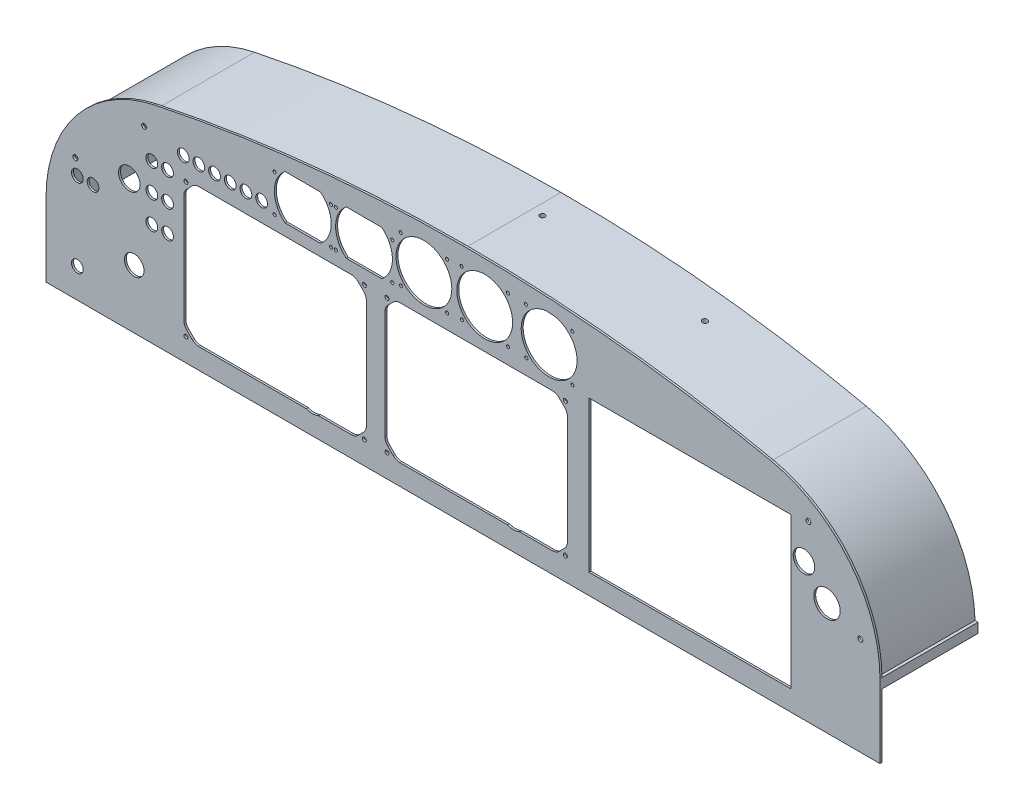
from build123d import *

# Parameters (mm, degrees)
SKETCH1_R           = 6
SKETCH1_R_2         = 2.032
SKETCH1_R_3         = 28.5
SKETCH1_R_4         = 1.6
SKETCH1_R_5         = 13.5
SKETCH1_R_6         = 10
SKETCH1_W           = 206
SKETCH1_H           = 154
BOSS_EXTRUDE1_DEPTH = 2
SKETCH3_R           = 2.5
SKETCH3_R_2         = 11
CUT_EXTRUDE1_DEPTH  = 2
EXTRUDE_THIN1_DEPTH = 100
CUT_EXTRUDE2_REACH  = 245.912
SKETCH6_R           = 2.635
SKETCH6_R_2         = 2.634583067


with BuildPart() as part:
    # Sketch1 → Boss-Extrude1 (new body)
    with BuildSketch(Plane.XY):
        with BuildLine():
            Line((649.441186223, 140.307443973), (649.441186223, 155.307443973))
            Line((649.441186223, 155.307443973), (649.441186223, 215.307443973))
            ThreePointArc((649.441186223, 215.307443973), (680.667313691, 303.445090041), (760.416109856, 352.265630811))
            ThreePointArc((760.416109856, 352.265630811), (916.817397977, 376.984778219), (1074.941186222, 385.307443973))
            ThreePointArc((1074.941186222, 385.307443973), (1233.073283535, 377.06387223), (1389.46626259, 352.265630811))
            ThreePointArc((1389.46626259, 352.265630811), (1469.176407606, 303.413771662), (1500.441186223, 215.307443974))
            Line((1500.441186223, 215.307443974), (1500.441186223, 140.307443973))
            Line((1500.441186223, 140.307443973), (649.441186223, 140.307443973))
        make_face()
        with Locations((853.441186223, 322.307443973)):
            Circle(SKETCH1_R, mode=Mode.SUBTRACT)
        with Locations((869.441186223, 322.307443973)):
            Circle(SKETCH1_R, mode=Mode.SUBTRACT)
        with Locations((997.365509528, 163.658286206)):
            Circle(SKETCH1_R_2, mode=Mode.SUBTRACT)
        with Locations((1179.465509529, 163.658286206)):
            Circle(SKETCH1_R_2, mode=Mode.SUBTRACT)
        with Locations((1179.465509529, 300.358286207)):
            Circle(SKETCH1_R_2, mode=Mode.SUBTRACT)
        with Locations((997.365509528, 300.358286207)):
            Circle(SKETCH1_R_2, mode=Mode.SUBTRACT)
        with Locations((792.197979152, 163.658286206)):
            Circle(SKETCH1_R_2, mode=Mode.SUBTRACT)
        with Locations((974.297979153, 163.658286206)):
            Circle(SKETCH1_R_2, mode=Mode.SUBTRACT)
        with Locations((974.297979153, 300.358286207)):
            Circle(SKETCH1_R_2, mode=Mode.SUBTRACT)
        with Locations((792.197979152, 300.358286207)):
            Circle(SKETCH1_R_2, mode=Mode.SUBTRACT)
        with Locations((1162.812861584, 341.737114485)):
            Circle(SKETCH1_R_3, mode=Mode.SUBTRACT)
        with Locations((1139.124784415, 365.425191654)):
            Circle(SKETCH1_R_4, mode=Mode.SUBTRACT)
        with Locations((1186.500938754, 318.049037315)):
            Circle(SKETCH1_R_4, mode=Mode.SUBTRACT)
        with Locations((1186.500938754, 365.425191654)):
            Circle(SKETCH1_R_4, mode=Mode.SUBTRACT)
        with Locations((1097.100872713, 342.607531463)):
            Circle(SKETCH1_R_3, mode=Mode.SUBTRACT)
        with Locations((1073.412795543, 366.295608633)):
            Circle(SKETCH1_R_4, mode=Mode.SUBTRACT)
        with Locations((1120.788949883, 318.919454293)):
            Circle(SKETCH1_R_4, mode=Mode.SUBTRACT)
        with Locations((1120.788949883, 366.295608633)):
            Circle(SKETCH1_R_4, mode=Mode.SUBTRACT)
        with Locations((1035.032848324, 341.476660494)):
            Circle(SKETCH1_R_3, mode=Mode.SUBTRACT)
        with Locations((1011.344771154, 365.164737664)):
            Circle(SKETCH1_R_4, mode=Mode.SUBTRACT)
        with Locations((1058.720925493, 317.788583324)):
            Circle(SKETCH1_R_4, mode=Mode.SUBTRACT)
        with Locations((1058.720925493, 365.164737664)):
            Circle(SKETCH1_R_4, mode=Mode.SUBTRACT)
        with Locations((789.441186223, 322.307443973)):
            Circle(SKETCH1_R, mode=Mode.SUBTRACT)
        with Locations((805.441186223, 322.307443973)):
            Circle(SKETCH1_R, mode=Mode.SUBTRACT)
        with Locations((821.441186223, 322.307443973)):
            Circle(SKETCH1_R, mode=Mode.SUBTRACT)
        with Locations((837.441186223, 322.307443973)):
            Circle(SKETCH1_R, mode=Mode.SUBTRACT)
        with Locations((1446.334241948, 254.799678315)):
            Circle(SKETCH1_R_5, mode=Mode.SUBTRACT)
        with Locations((945.141186223, 354.307443973)):
            Circle(SKETCH1_R_4, mode=Mode.SUBTRACT)
        with Locations((945.141186223, 316.557443973)):
            Circle(SKETCH1_R_4, mode=Mode.SUBTRACT)
        with Locations((1002.741186223, 316.557443973)):
            Circle(SKETCH1_R_4, mode=Mode.SUBTRACT)
        with Locations((1002.741186223, 354.307443973)):
            Circle(SKETCH1_R_4, mode=Mode.SUBTRACT)
        with Locations((882.637630406, 354.307443973)):
            Circle(SKETCH1_R_4, mode=Mode.SUBTRACT)
        with Locations((882.638024981, 316.557443973)):
            Circle(SKETCH1_R_4, mode=Mode.SUBTRACT)
        with Locations((940.241186223, 316.557443973)):
            Circle(SKETCH1_R_4, mode=Mode.SUBTRACT)
        with Locations((940.241186223, 354.307443973)):
            Circle(SKETCH1_R_4, mode=Mode.SUBTRACT)
        with Locations((739.441186223, 200.307443973)):
            Circle(SKETCH1_R_6, mode=Mode.SUBTRACT)
        with Locations((757.441186223, 301.307443973)):
            Circle(SKETCH1_R, mode=Mode.SUBTRACT)
        with Locations((773.441186223, 301.307443973)):
            Circle(SKETCH1_R, mode=Mode.SUBTRACT)
        with Locations((757.441186223, 273.307443973)):
            Circle(SKETCH1_R, mode=Mode.SUBTRACT)
        with Locations((773.441186223, 273.307443973)):
            Circle(SKETCH1_R, mode=Mode.SUBTRACT)
        with Locations((757.441186223, 245.307443973)):
            Circle(SKETCH1_R, mode=Mode.SUBTRACT)
        with Locations((773.465338198, 245.307443973)):
            Circle(SKETCH1_R, mode=Mode.SUBTRACT)
        with Locations((681.441186223, 250.307443973)):
            Circle(SKETCH1_R, mode=Mode.SUBTRACT)
        with Locations((697.441186223, 250.307443973)):
            Circle(SKETCH1_R, mode=Mode.SUBTRACT)
        with Locations((681.441186223, 170.307443973)):
            Circle(SKETCH1_R, mode=Mode.SUBTRACT)
        with Locations((1011.744677557, 318.188489728)):
            Circle(SKETCH1_R_4, mode=Mode.SUBTRACT)
        with Locations((1073.812701947, 319.319360697)):
            Circle(SKETCH1_R_4, mode=Mode.SUBTRACT)
        with Locations((1139.524690818, 318.448943718)):
            Circle(SKETCH1_R_4, mode=Mode.SUBTRACT)
        with Locations((1306.499876327, 237.973427273)):
            Rectangle(SKETCH1_W, SKETCH1_H, mode=Mode.SUBTRACT)
        with BuildLine():
            Line((1132.564696468, 161.308286207), (1166.059665407, 161.308286207))
            ThreePointArc((1166.059665407, 161.308286207), (1169.886499731, 162.069490882), (1173.130733219, 164.237218395))
            Line((1173.130733219, 164.237218395), (1178.58657734, 169.693062517))
            ThreePointArc((1178.58657734, 169.693062517), (1180.754304854, 172.937296005), (1181.515509528, 176.764130329))
            Line((1181.515509528, 176.764130329), (1181.515509528, 287.252442082))
            ThreePointArc((1181.515509528, 287.252442082), (1180.754304854, 291.079276405), (1178.58657734, 294.323509894))
            Line((1178.58657734, 294.323509894), (1173.130733219, 299.779354015))
            ThreePointArc((1173.130733219, 299.779354015), (1169.886499731, 301.947081528), (1166.059665407, 302.708286203))
            Line((1166.059665407, 302.708286203), (1010.77135365, 302.708286203))
            ThreePointArc((1010.77135365, 302.708286203), (1006.944519327, 301.947081528), (1003.700285839, 299.779354015))
            Line((1003.700285839, 299.779354015), (998.244441717, 294.323509894))
            ThreePointArc((998.244441717, 294.323509894), (996.076714204, 291.079276405), (995.315509529, 287.252442082))
            Line((995.315509529, 287.252442082), (995.315509529, 176.764130329))
            ThreePointArc((995.315509529, 176.764130329), (996.076714204, 172.937296005), (998.244441717, 169.693062517))
            Line((998.244441717, 169.693062517), (1003.700285838, 164.237218395))
            ThreePointArc((1003.700285838, 164.237218395), (1006.944519327, 162.069490882), (1010.77135365, 161.308286207))
            Line((1010.77135365, 161.308286207), (1120.266322591, 161.308286207))
            ThreePointArc((1120.266322591, 161.308286207), (1126.415509529, 160.058286207), (1132.564696468, 161.308286207))
        make_face(mode=Mode.SUBTRACT)
        with BuildLine():
            Line((927.397166092, 161.308286207), (960.892135031, 161.308286207))
            ThreePointArc((960.892135031, 161.308286207), (964.718969354, 162.069490882), (967.963202843, 164.237218395))
            Line((967.963202843, 164.237218395), (973.419046964, 169.693062517))
            ThreePointArc((973.419046964, 169.693062517), (975.586774477, 172.937296005), (976.347979152, 176.764130329))
            Line((976.347979152, 176.764130329), (976.347979152, 287.252442082))
            ThreePointArc((976.347979152, 287.252442082), (975.586774477, 291.079276405), (973.419046964, 294.323509894))
            Line((973.419046964, 294.323509894), (967.963202843, 299.779354015))
            ThreePointArc((967.963202843, 299.779354015), (964.718969354, 301.947081528), (960.892135031, 302.708286203))
            Line((960.892135031, 302.708286203), (805.603823274, 302.708286203))
            ThreePointArc((805.603823274, 302.708286203), (801.776988951, 301.947081528), (798.532755462, 299.779354015))
            Line((798.532755462, 299.779354015), (793.076911341, 294.323509894))
            ThreePointArc((793.076911341, 294.323509894), (790.909183828, 291.079276405), (790.147979153, 287.252442082))
            Line((790.147979153, 287.252442082), (790.147979153, 176.764130329))
            ThreePointArc((790.147979153, 176.764130329), (790.909183828, 172.937296005), (793.076911341, 169.693062517))
            Line((793.076911341, 169.693062517), (798.532755462, 164.237218395))
            ThreePointArc((798.532755462, 164.237218395), (801.776988951, 162.069490882), (805.603823274, 161.308286207))
            Line((805.603823274, 161.308286207), (915.098792215, 161.308286207))
            ThreePointArc((915.098792215, 161.308286207), (921.247979153, 160.058286207), (927.397166092, 161.308286207))
        make_face(mode=Mode.SUBTRACT)
        with BuildLine():
            Line((955.893748732, 360.007443973), (991.988623714, 360.007443973))
            ThreePointArc((991.988623714, 360.007443973), (1002.941186223, 337.307443973), (991.988623714, 314.607443973))
            Line((991.988623714, 314.607443973), (955.893748732, 314.607443973))
            ThreePointArc((955.893748732, 314.607443973), (944.941186223, 337.307443973), (955.893748732, 360.007443973))
        make_face(mode=Mode.SUBTRACT)
        with BuildLine():
            Line((893.393748732, 360.007443973), (929.488623714, 360.007443973))
            ThreePointArc((929.488623714, 360.007443973), (940.441186223, 337.307443973), (929.488623714, 314.607443973))
            Line((929.488623714, 314.607443973), (893.393748732, 314.607443973))
            ThreePointArc((893.393748732, 314.607443973), (882.441186223, 337.307443973), (893.393748732, 360.007443973))
        make_face(mode=Mode.SUBTRACT)
    extrude(amount=BOSS_EXTRUDE1_DEPTH)

    # Sketch3 → Cut-Extrude1 (cut)
    with BuildSketch(Plane.XY.offset(2)):
        with Locations((679.441186223, 265.307443973)):
            Circle(SKETCH3_R)
        with Locations((749.441186223, 328.044992539)):
            Circle(SKETCH3_R)
        with Locations((734.441186223, 274.315517846)):
            Circle(SKETCH3_R_2)
        with Locations((1427.441186223, 317.941199518)):
            Circle(SKETCH3_R)
        with Locations((1480.441186223, 240.307443973)):
            Circle(SKETCH3_R)
        with Locations((1422.863139552, 280.307443973)):
            Circle(SKETCH3_R_2)
    extrude(amount=-CUT_EXTRUDE1_DEPTH, mode=Mode.SUBTRACT)

    # Sketch4 → Extrude-Thin1 (add)
    with BuildSketch(Plane.XY.offset(2)):
        with BuildLine():
            Line((649.441186223, 215.307443973), (652.441186223, 215.307443973))
            ThreePointArc((652.441186223, 215.307443973), (683.387006086, 302.178127225), (762.285370604, 349.919173001))
            ThreePointArc((762.285370604, 349.919173001), (917.813267517, 373.836106026), (1074.941186222, 382.307443973))
            ThreePointArc((1074.941186222, 382.307443973), (1231.614699966, 374.375404156), (1386.46626259, 349.265630811))
            ThreePointArc((1386.46626259, 349.265630811), (1465.012517726, 301.389123714), (1497.441186223, 215.307443973))
            Line((1497.441186223, 215.307443973), (1500.441186223, 215.307443974))
            Line((1500.441186223, 215.307443974), (1500.441186224, 205.307443974))
            Line((1500.441186224, 205.307443974), (1487.364875945, 205.307443972))
            ThreePointArc((1487.364875945, 205.307443972), (1460.340852091, 291.2123248), (1384.324586293, 339.497661593))
            ThreePointArc((1384.324586293, 339.497661593), (1230.559969107, 364.431182577), (1074.986189575, 372.307545239))
            ThreePointArc((1074.986189575, 372.307545239), (918.843661817, 363.889333303), (764.291121689, 340.122389724))
            ThreePointArc((764.291121689, 340.122389724), (688.047410052, 291.916793306), (662.834244874, 205.307443973))
            Line((662.834244874, 205.307443973), (649.441186223, 205.307443973))
            Line((649.441186223, 205.307443973), (649.441186223, 215.307443973))
        make_face()
    extrude(amount=-EXTRUDE_THIN1_DEPTH)

    # Sketch6 → Cut-Extrude2 (cut, up to next)
    with BuildSketch(Plane(origin=(-1.698723429, 377.462154406, 0), x_dir=(0.999989873, 0.004500335, 0), z_dir=(-0.004500335, 0.999989873, 0)), mode=Mode.PRIVATE) as cut_extrude2_sk1:
        with Locations((1253.457334551, 68)):
            Circle(SKETCH6_R)
    cut_extrude2_tool1 = extrude(cut_extrude2_sk1.sketch, amount=-CUT_EXTRUDE2_REACH, mode=Mode.PRIVATE) & part.part
    add(cut_extrude2_tool1.solids().sort_by_distance((1251.745918, 383.103133, -68))[0], mode=Mode.SUBTRACT)
    # Sketch6 → Cut-Extrude2 (cut, up to next)
    with BuildSketch(Plane(origin=(-1.698723429, 377.462154406, 0), x_dir=(0.999989873, 0.004500335, 0), z_dir=(-0.004500335, 0.999989873, 0)), mode=Mode.PRIVATE) as cut_extrude2_sk2:
        with Locations((1087.728332004, 68)):
            Circle(SKETCH6_R_2)
    cut_extrude2_tool2 = extrude(cut_extrude2_sk2.sketch, amount=-CUT_EXTRUDE2_REACH, mode=Mode.PRIVATE) & part.part
    add(cut_extrude2_tool2.solids().sort_by_distance((1086.018594, 382.357297, -68))[0], mode=Mode.SUBTRACT)


solid = part.part
